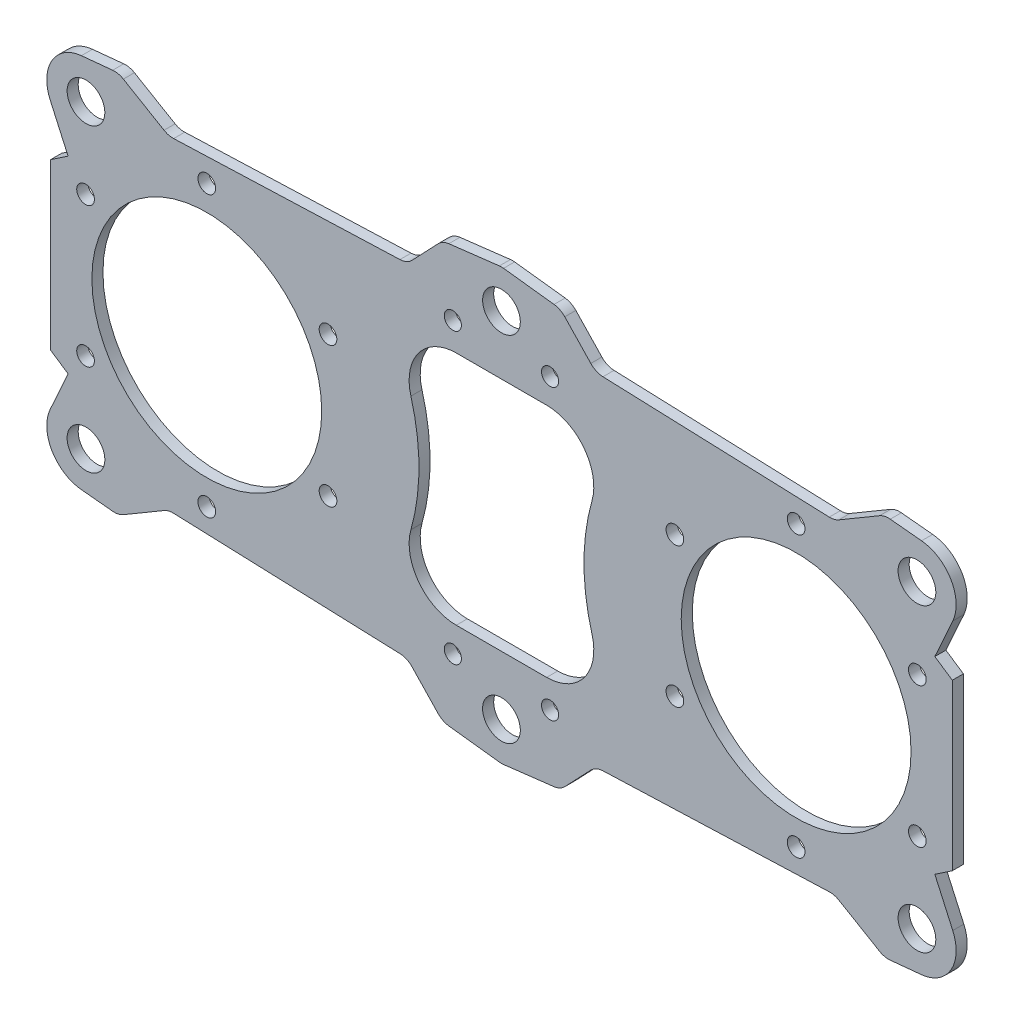
from build123d import *

# Parameters (mm, degrees)
SKETCH1_R           = 3.2
SKETCH1_R_2         = 19.5
BOSS_EXTRUDE1_DEPTH = 1.8796
CUT_EXTRUDE1_DEPTH  = 2.8796
SKETCH3_R           = 3.2
BOSS_EXTRUDE2_DEPTH = 1.8796
FILLET1_R           = 6.5
SKETCH4_R           = 1.5
CUT_EXTRUDE2_DEPTH  = 2.8796
FILLET2_R           = 8
SKETCH6_R           = 1.45
CUT_EXTRUDE4_DEPTH  = 2.8796
FILLET3_R           = 3


with BuildPart() as part:
    # Sketch1 → Boss-Extrude1 (new body)
    with BuildSketch(Plane.XY):
        Polygon((0, 36.5), (-10, 35.30709832), (-16, 29), (-56.5, 27.5), (-76.5, 14), (-76.5, -14), (-56.5, -27.5), (-16, -29), (-10, -35.30709832), (0, -36.5), (10, -35.30709832), (16, -29), (56.5, -27.5), (76.5, -14), (76.5, 14), (56.5, 27.5), (16, 29), (10, 35.30709832), align=None)
        with Locations((0, 30)):
            Circle(SKETCH1_R, mode=Mode.SUBTRACT)
        with Locations((-50, 0)):
            Circle(SKETCH1_R_2, mode=Mode.SUBTRACT)
        with Locations((50, 0)):
            Circle(SKETCH1_R_2, mode=Mode.SUBTRACT)
        with Locations((0, -30)):
            Circle(SKETCH1_R, mode=Mode.SUBTRACT)
    extrude(amount=BOSS_EXTRUDE1_DEPTH)

    # Sketch2 → Cut-Extrude1 (cut, through all)
    with BuildSketch(Plane.XY.offset(1.8796)):
        with BuildLine():
            Line((-20.066740906, 20), (20.066740906, 20))
            ThreePointArc((20.066740906, 20), (14, 0), (20.066740906, -20))
            Line((20.066740906, -20), (-20.066740906, -20))
            ThreePointArc((-20.066740906, -20), (-14, 0), (-20.066740906, 20))
        make_face()
    extrude(amount=-CUT_EXTRUDE1_DEPTH, mode=Mode.SUBTRACT)

    # Sketch3 → Boss-Extrude2 (add)
    with BuildSketch(Plane.XY.offset(1.8796)):
        Polygon((-56.5, 27.5), (-65, 32.5), (-80.3, 31), (-73.537037037, 16), align=None)
        with Locations((-70.5, 25.5)):
            Circle(SKETCH3_R, mode=Mode.SUBTRACT)
        Polygon((73.537037037, 16), (56.5, 27.5), (65, 32.5), (80.3, 31), align=None)
        with Locations((70.5, 25.5)):
            Circle(SKETCH3_R, mode=Mode.SUBTRACT)
        Polygon((56.5, -27.5), (65, -32.5), (80.3, -31), (73.537037037, -16), align=None)
        with Locations((70.5, -25.5)):
            Circle(SKETCH3_R, mode=Mode.SUBTRACT)
        Polygon((-73.537037037, -16), (-56.5, -27.5), (-65, -32.5), (-80.3, -31), align=None)
        with Locations((-70.5, -25.5)):
            Circle(SKETCH3_R, mode=Mode.SUBTRACT)
    extrude(amount=-BOSS_EXTRUDE2_DEPTH)

    # Fillet1
    fillet1_edges = [part.edges().sort_by_distance(p)[0] for p in [
        (80.3, -31, 0.9398),
        (-80.3, -31, 0.9398),
        (-80.3, 31, 0.9398),
        (80.3, 31, 0.9398),
    ]]
    fillet(fillet1_edges, radius=FILLET1_R)

    # Sketch4 → Cut-Extrude2 (cut, through all)
    with BuildSketch(Plane.XY.offset(1.8796)):
        with Locations((-50, 23.75)):
            Circle(SKETCH4_R)
        with Locations((-70.56810334, 11.875)):
            Circle(SKETCH4_R)
        with Locations((-70.56810334, -11.875)):
            Circle(SKETCH4_R)
        with Locations((-50, -23.75)):
            Circle(SKETCH4_R)
        with Locations((-29.43189666, -11.875)):
            Circle(SKETCH4_R)
        with Locations((-29.43189666, 11.875)):
            Circle(SKETCH4_R)
        with Locations((29.43189666, 11.875)):
            Circle(SKETCH4_R)
        with Locations((29.43189666, -11.875)):
            Circle(SKETCH4_R)
        with Locations((50, -23.75)):
            Circle(SKETCH4_R)
        with Locations((70.56810334, -11.875)):
            Circle(SKETCH4_R)
        with Locations((70.56810334, 11.875)):
            Circle(SKETCH4_R)
        with Locations((50, 23.75)):
            Circle(SKETCH4_R)
    extrude(amount=-CUT_EXTRUDE2_DEPTH, mode=Mode.SUBTRACT)

    # Fillet2
    fillet2_edges = [part.edges().sort_by_distance(p)[0] for p in [
        (-20.066740906, -20, 0.9398),
        (-20.066740906, 20, 0.9398),
        (20.066740906, 20, 0.9398),
        (20.066740906, -20, 0.9398),
    ]]
    fillet(fillet2_edges, radius=FILLET2_R)

    # Sketch6 → Cut-Extrude4 (cut, through all)
    with BuildSketch(Plane(origin=(0, 0, 0), x_dir=(-1, 0, 0), z_dir=(0, 0, -1))):
        with Locations((8.25, 24.5)):
            Circle(SKETCH6_R)
        with Locations((-8.25, 24.5)):
            Circle(SKETCH6_R)
        with Locations((-8.25, -24.5)):
            Circle(SKETCH6_R)
        with Locations((8.25, -24.5)):
            Circle(SKETCH6_R)
    extrude(amount=-CUT_EXTRUDE4_DEPTH, mode=Mode.SUBTRACT)

    # Fillet3
    fillet3_edges = [part.edges().sort_by_distance(p)[0] for p in [
        (65, -32.5, 0.9398),
        (-65, -32.5, 0.9398),
        (10, 35.30709832, 0.9398),
        (16, 29, 0.9398),
        (56.5, 27.5, 0.9398),
        (56.5, -27.5, 0.9398),
        (16, -29, 0.9398),
        (10, -35.30709832, 0.9398),
        (0, -36.5, 0.9398),
        (-10, -35.30709832, 0.9398),
        (-16, -29, 0.9398),
        (-56.5, -27.5, 0.9398),
        (-56.5, 27.5, 0.9398),
        (-16, 29, 0.9398),
        (-10, 35.30709832, 0.9398),
        (0, 36.5, 0.9398),
        (-65, 32.5, 0.9398),
        (65, 32.5, 0.9398),
    ]]
    fillet(fillet3_edges, radius=FILLET3_R)


solid = part.part
